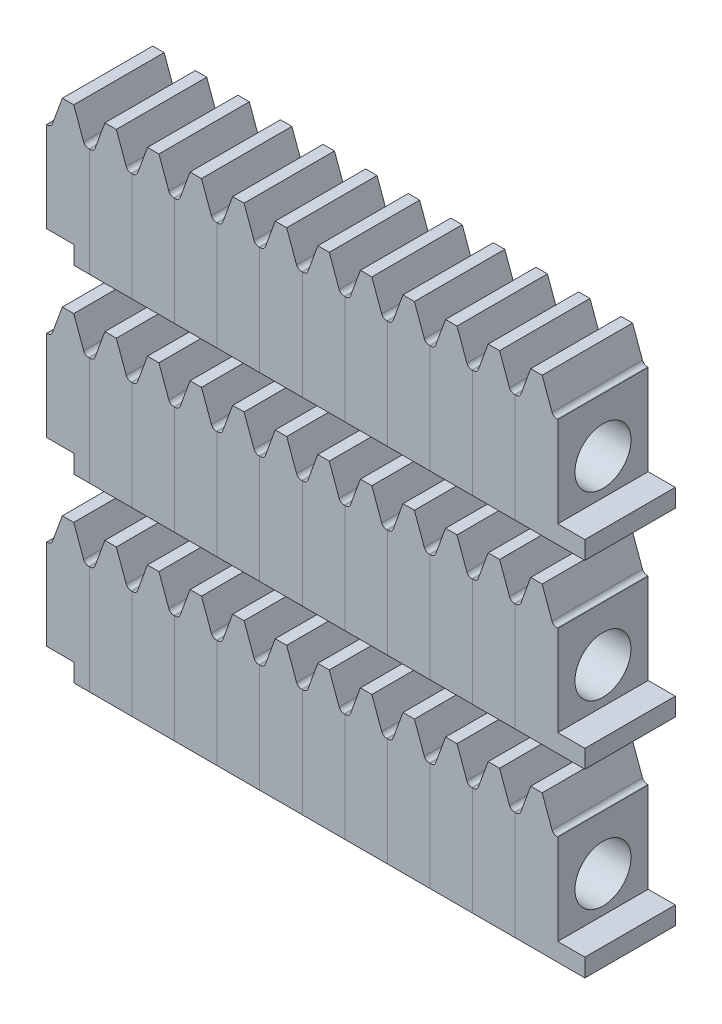
from build123d import *

# Parameters (mm, degrees)
MAIN_DEPTH          = 10
SKETCH2_W           = 4.721082869
SKETCH2_H           = 12
SUPPORT_DEPTH       = 10
SKETCH3_R           = 3.1
AXISHOLE_DEPTH      = 5.721082869
FILLET1_R           = 0.57
LPATTERN2_COUNT     = 12
LPATTERN2_PITCH     = 4.71
SKETCH4_W           = 10
SKETCH4_H           = 2
BOSS_EXTRUDE1_DEPTH = 3
SKETCH5_W           = 10
SKETCH5_H           = 2
CUT_EXTRUDE1_DEPTH  = 3
LPATTERN3_COUNT     = 3
LPATTERN3_PITCH     = 20


with BuildPart() as part:
    # Sketch1 → Main (new body)
    with BuildSketch(Plane.XY):
        Polygon((-3.721082869, 0), (-2.492683328, 3.375), (-1.228399541, 3.375), (0, 0), align=None)
    extrude(amount=MAIN_DEPTH)

    # Sketch2 → Support (add)
    with BuildSketch(Plane.XY.offset(10)):
        with Locations((-1.860541434, -6)):
            Rectangle(SKETCH2_W, SKETCH2_H)
    extrude(amount=-SUPPORT_DEPTH)

    # Sketch3 → AxisHole (cut, through all)
    with BuildSketch(Plane.ZY.offset(4.221082869)):
        with Locations((5, -6)):
            Circle(SKETCH3_R)
    extrude(amount=-AXISHOLE_DEPTH, mode=Mode.SUBTRACT)

    # Fillet1
    fillet1_edges = [part.edges().sort_by_distance(p)[0] for p in [
        (-3.721082869, 0, 5),
        (0, 0, 5),
    ]]
    fillet(fillet1_edges, radius=FILLET1_R)


with BuildPart() as lpattern2_1:
    # LPattern2: pattern copy
    add(part.part.moved(Location(Vector(-1, 0, 0) * (1 * LPATTERN2_PITCH))))


with BuildPart() as lpattern2_2:
    # LPattern2: pattern copy
    add(part.part.moved(Location(Vector(-1, 0, 0) * (2 * LPATTERN2_PITCH))))


with BuildPart() as lpattern2_3:
    # LPattern2: pattern copy
    add(part.part.moved(Location(Vector(-1, 0, 0) * (3 * LPATTERN2_PITCH))))


with BuildPart() as lpattern2_4:
    # LPattern2: pattern copy
    add(part.part.moved(Location(Vector(-1, 0, 0) * (4 * LPATTERN2_PITCH))))


with BuildPart() as lpattern2_5:
    # LPattern2: pattern copy
    add(part.part.moved(Location(Vector(-1, 0, 0) * (5 * LPATTERN2_PITCH))))


with BuildPart() as lpattern2_6:
    # LPattern2: pattern copy
    add(part.part.moved(Location(Vector(-1, 0, 0) * (6 * LPATTERN2_PITCH))))


with BuildPart() as lpattern2_7:
    # LPattern2: pattern copy
    add(part.part.moved(Location(Vector(-1, 0, 0) * (7 * LPATTERN2_PITCH))))


with BuildPart() as lpattern2_8:
    # LPattern2: pattern copy
    add(part.part.moved(Location(Vector(-1, 0, 0) * (8 * LPATTERN2_PITCH))))


with BuildPart() as lpattern2_9:
    # LPattern2: pattern copy
    add(part.part.moved(Location(Vector(-1, 0, 0) * (9 * LPATTERN2_PITCH))))


with BuildPart() as lpattern2_10:
    # LPattern2: pattern copy
    add(part.part.moved(Location(Vector(-1, 0, 0) * (10 * LPATTERN2_PITCH))))


with BuildPart() as lpattern2_11:
    # LPattern2: pattern copy
    add(part.part.moved(Location(Vector(-1, 0, 0) * (11 * LPATTERN2_PITCH))))

    # Sketch5 → Cut-Extrude1 (cut)
    with BuildSketch(Plane.ZY.offset(56.031082869)):
        with Locations((5, -11)):
            Rectangle(SKETCH5_W, SKETCH5_H)
    extrude(amount=-CUT_EXTRUDE1_DEPTH, mode=Mode.SUBTRACT)


with BuildPart() as part_1:
    add(part.part)

    # Sketch4 → Boss-Extrude1 (add)
    with BuildSketch(Plane(origin=(0.5, 0, 0), x_dir=(0, 0, -1), z_dir=(1, 0, 0))):
        with Locations((-5, -11)):
            Rectangle(SKETCH4_W, SKETCH4_H)
    extrude(amount=BOSS_EXTRUDE1_DEPTH)


with BuildPart() as lpattern3_1:
    # LPattern3: pattern copy
    add(lpattern2_11.part.moved(Location(Vector(0, -1, 0) * (1 * LPATTERN3_PITCH))))


with BuildPart() as lpattern3_2:
    # LPattern3: pattern copy
    add(lpattern2_11.part.moved(Location(Vector(0, -1, 0) * (2 * LPATTERN3_PITCH))))


with BuildPart() as lpattern3_3:
    # LPattern3: pattern copy
    add(lpattern2_10.part.moved(Location(Vector(0, -1, 0) * (1 * LPATTERN3_PITCH))))


with BuildPart() as lpattern3_4:
    # LPattern3: pattern copy
    add(lpattern2_10.part.moved(Location(Vector(0, -1, 0) * (2 * LPATTERN3_PITCH))))


with BuildPart() as lpattern3_5:
    # LPattern3: pattern copy
    add(lpattern2_9.part.moved(Location(Vector(0, -1, 0) * (1 * LPATTERN3_PITCH))))


with BuildPart() as lpattern3_6:
    # LPattern3: pattern copy
    add(lpattern2_9.part.moved(Location(Vector(0, -1, 0) * (2 * LPATTERN3_PITCH))))


with BuildPart() as lpattern3_7:
    # LPattern3: pattern copy
    add(lpattern2_8.part.moved(Location(Vector(0, -1, 0) * (1 * LPATTERN3_PITCH))))


with BuildPart() as lpattern3_8:
    # LPattern3: pattern copy
    add(lpattern2_8.part.moved(Location(Vector(0, -1, 0) * (2 * LPATTERN3_PITCH))))


with BuildPart() as lpattern3_9:
    # LPattern3: pattern copy
    add(lpattern2_7.part.moved(Location(Vector(0, -1, 0) * (1 * LPATTERN3_PITCH))))


with BuildPart() as lpattern3_10:
    # LPattern3: pattern copy
    add(lpattern2_7.part.moved(Location(Vector(0, -1, 0) * (2 * LPATTERN3_PITCH))))


with BuildPart() as lpattern3_11:
    # LPattern3: pattern copy
    add(lpattern2_6.part.moved(Location(Vector(0, -1, 0) * (1 * LPATTERN3_PITCH))))


with BuildPart() as lpattern3_12:
    # LPattern3: pattern copy
    add(lpattern2_6.part.moved(Location(Vector(0, -1, 0) * (2 * LPATTERN3_PITCH))))


with BuildPart() as lpattern3_13:
    # LPattern3: pattern copy
    add(lpattern2_5.part.moved(Location(Vector(0, -1, 0) * (1 * LPATTERN3_PITCH))))


with BuildPart() as lpattern3_14:
    # LPattern3: pattern copy
    add(lpattern2_5.part.moved(Location(Vector(0, -1, 0) * (2 * LPATTERN3_PITCH))))


with BuildPart() as lpattern3_15:
    # LPattern3: pattern copy
    add(lpattern2_4.part.moved(Location(Vector(0, -1, 0) * (1 * LPATTERN3_PITCH))))


with BuildPart() as lpattern3_16:
    # LPattern3: pattern copy
    add(lpattern2_4.part.moved(Location(Vector(0, -1, 0) * (2 * LPATTERN3_PITCH))))


with BuildPart() as lpattern3_17:
    # LPattern3: pattern copy
    add(lpattern2_3.part.moved(Location(Vector(0, -1, 0) * (1 * LPATTERN3_PITCH))))


with BuildPart() as lpattern3_18:
    # LPattern3: pattern copy
    add(lpattern2_3.part.moved(Location(Vector(0, -1, 0) * (2 * LPATTERN3_PITCH))))


with BuildPart() as lpattern3_19:
    # LPattern3: pattern copy
    add(lpattern2_2.part.moved(Location(Vector(0, -1, 0) * (1 * LPATTERN3_PITCH))))


with BuildPart() as lpattern3_20:
    # LPattern3: pattern copy
    add(lpattern2_2.part.moved(Location(Vector(0, -1, 0) * (2 * LPATTERN3_PITCH))))


with BuildPart() as lpattern3_21:
    # LPattern3: pattern copy
    add(lpattern2_1.part.moved(Location(Vector(0, -1, 0) * (1 * LPATTERN3_PITCH))))


with BuildPart() as lpattern3_22:
    # LPattern3: pattern copy
    add(lpattern2_1.part.moved(Location(Vector(0, -1, 0) * (2 * LPATTERN3_PITCH))))


with BuildPart() as lpattern3_23:
    # LPattern3: pattern copy
    add(part_1.part.moved(Location(Vector(0, -1, 0) * (1 * LPATTERN3_PITCH))))


with BuildPart() as lpattern3_24:
    # LPattern3: pattern copy
    add(part_1.part.moved(Location(Vector(0, -1, 0) * (2 * LPATTERN3_PITCH))))


solid = Compound([lpattern2_1.part, lpattern2_2.part, lpattern2_3.part, lpattern2_4.part, lpattern2_5.part, lpattern2_6.part, lpattern2_7.part, lpattern2_8.part, lpattern2_9.part, lpattern2_10.part, lpattern2_11.part, part_1.part, lpattern3_1.part, lpattern3_2.part, lpattern3_3.part, lpattern3_4.part, lpattern3_5.part, lpattern3_6.part, lpattern3_7.part, lpattern3_8.part, lpattern3_9.part, lpattern3_10.part, lpattern3_11.part, lpattern3_12.part, lpattern3_13.part, lpattern3_14.part, lpattern3_15.part, lpattern3_16.part, lpattern3_17.part, lpattern3_18.part, lpattern3_19.part, lpattern3_20.part, lpattern3_21.part, lpattern3_22.part, lpattern3_23.part, lpattern3_24.part])
